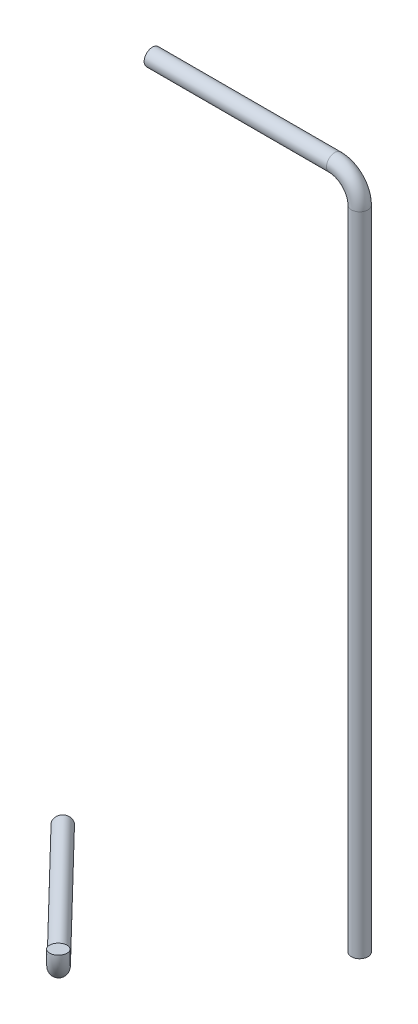
from build123d import *

# Parameters (mm, degrees)
SKETCH3_R = 1
SKETCH6_R = 1


with BuildPart() as part:
    # Sweep1: sweep along a path in Sketch1
    with BuildLine(Plane.XY) as sweep1_path:
        Line((0, 0), (22, 0))
        ThreePointArc((22, 0), (24.121320344, -0.878679656), (25, -3))
        Line((25, -3), (25, -81.02))
    # Sketch3 → Sweep1 (sweep)
    with BuildSketch(Plane(origin=(0, 0, 0), x_dir=(0, 0, -1), z_dir=(1, 0, 0))):
        Circle(SKETCH3_R)
    sweep(path=sweep1_path.line)


with BuildPart() as body_2:
    # Sweep3: sweep along a path in Sketch4
    with BuildLine(Plane(origin=(-5.562759222, 0, 5.381828123), x_dir=(-0.6953221964979748, 0, -0.718698158518047), z_dir=(0.718698158518047, 0, -0.6953221964979748))) as sweep3_path:
        Line((5.60792605, -84.252449737), (-14.39207395, -84.252449737))
        ThreePointArc((-14.39207395, -84.252449737), (-16.594044568, -83.289929895), (-17.383054912, -81.02))
    # Sketch6 → Sweep3 (sweep)
    with BuildSketch(Plane(origin=(-9.462074682, -84.252449737, 1.351421997), x_dir=(-0.718698158518047, 0, 0.6953221964979748), z_dir=(-0.6953221964979748, 1.3877787807814465e-15, -0.718698158518047))):
        Circle(SKETCH6_R)
    sweep(path=sweep3_path.line)


solid = Compound([part.part, body_2.part])
